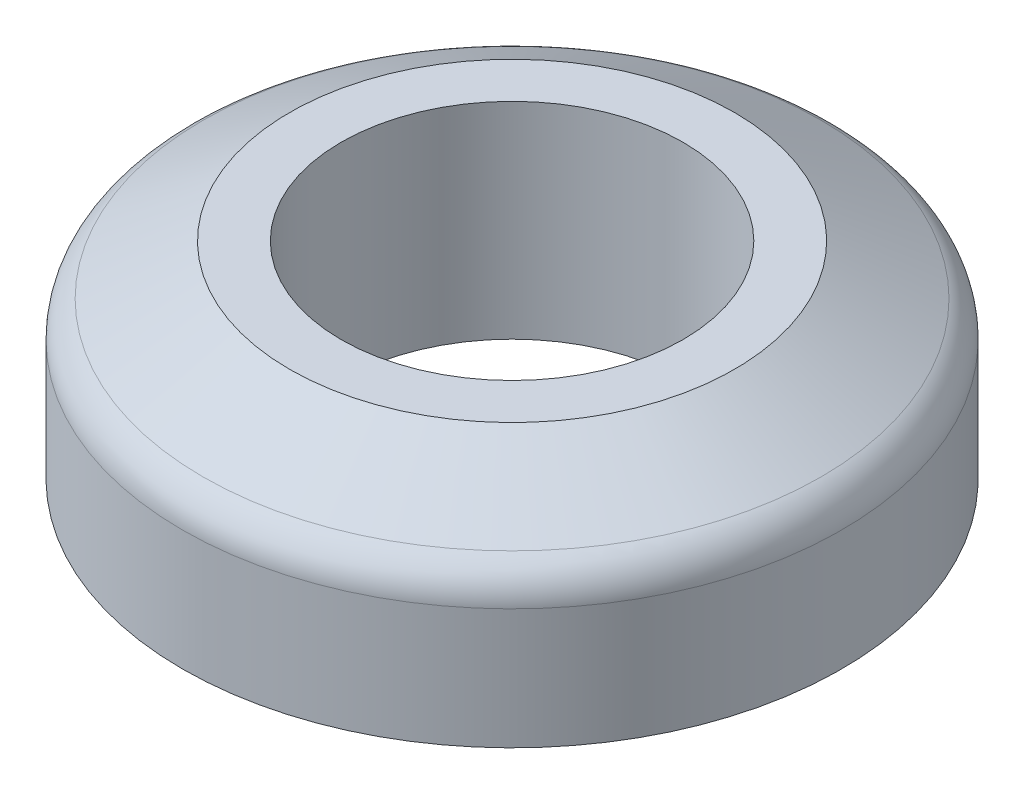
from build123d import *

# Parameters (mm, degrees)
SKETCH1_R           = 8
SKETCH1_R_2         = 4.15
BOSS_EXTRUDE1_DEPTH = 5
CHAMFER1_SIZE       = 2.6
CHAMFER1_SIZE2      = 1.5011107
FILLET1_R           = 1


with BuildPart() as part:
    # Sketch1 → Boss-Extrude1 (new body)
    with BuildSketch(Plane(origin=(0, 0, 0), x_dir=(1, 0, 0), z_dir=(0, 1, 0))):
        Circle(SKETCH1_R)
        Circle(SKETCH1_R_2, mode=Mode.SUBTRACT)
    extrude(amount=BOSS_EXTRUDE1_DEPTH)

    # Chamfer1
    chamfer1_edges = [part.edges().sort_by_distance(p)[0] for p in [
        (-8, 5, 0),
    ]]
    chamfer1_side = [part.faces().sort_by_distance(p)[0] for p in [
        (-7.77372583, 5, 0),
    ]]
    chamfer(chamfer1_edges, length=CHAMFER1_SIZE, length2=CHAMFER1_SIZE2, reference=chamfer1_side[0])

    # Fillet1
    fillet1_edges = [part.edges().sort_by_distance(p)[0] for p in [
        (-8, 3.4988893, 0),
    ]]
    fillet(fillet1_edges, radius=FILLET1_R)


solid = part.part
